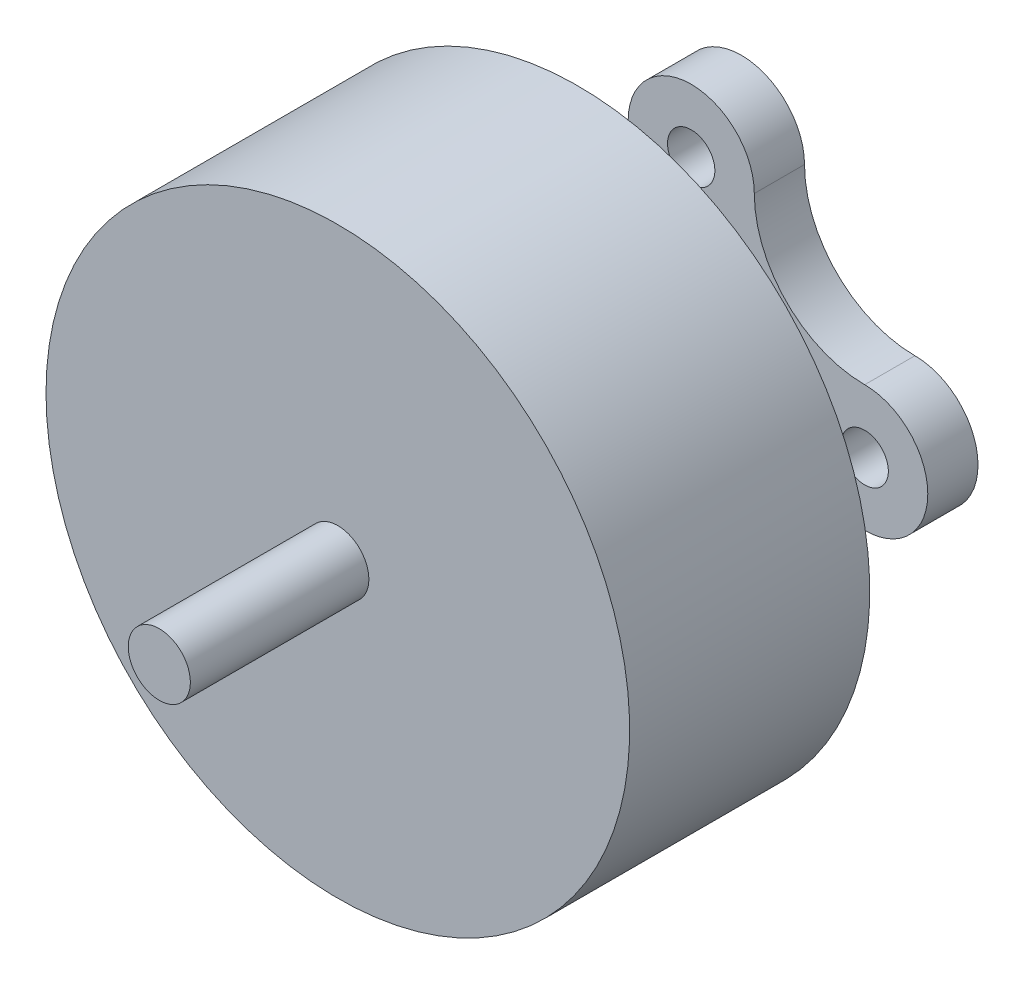
from build123d import *

# Parameters (mm, degrees)
SKETCH1_R           = 9.4
BOSS_EXTRUDE1_DEPTH = 13
SKETCH2_R           = 1
BOSS_EXTRUDE2_DEPTH = 5.75
SKETCH3_W           = 7.717079408
SKETCH3_H           = 3.649036098
SKETCH4_R           = 9.4
SKETCH4_R_2         = 0.762
CUT_EXTRUDE1_DEPTH  = 1.617316387


with BuildPart() as part:
    # Sketch1 → Boss-Extrude1 (new body)
    with BuildSketch(Plane.XY):
        with Locations(Location((0, 0, 0), (0, 0, 180))):
            Circle(SKETCH1_R)
    extrude(amount=BOSS_EXTRUDE1_DEPTH)

    # Sketch2 → Boss-Extrude2 (add)
    with BuildSketch(Plane.XY.offset(13)):
        Circle(SKETCH2_R)
    extrude(amount=BOSS_EXTRUDE2_DEPTH)

    # Sketch3 → Cut-Revolve1 (revolve, cut)
    with BuildSketch(Plane(origin=(0, 0, 0), x_dir=(1, 0, 0), z_dir=(0, 1, 0)), mode=Mode.PRIVATE) as cut_revolve1_sk:
        with Locations((5.541460296, -3.441834436)):
            Rectangle(SKETCH3_W, SKETCH3_H)
    revolve(cut_revolve1_sk.sketch.rotate(Axis((0, 0, 0), (0, 0, 1)), 180), axis=Axis((0, 0, 0), (0, 0, 1)), mode=Mode.SUBTRACT)

    # Sketch4 → Cut-Extrude1 (cut)
    with BuildSketch(Plane(origin=(0, 0, 0), x_dir=(-1, 0, 0), z_dir=(0, 0, -1))):
        Circle(SKETCH4_R)
        with BuildLine():
            ThreePointArc((-2.032, 5.588), (0, 7.62), (2.032, 5.588))
            ThreePointArc((2.032, 5.588), (3.073528286, 3.073528286), (5.588, 2.032))
            ThreePointArc((5.588, 2.032), (7.62, 0), (5.588, -2.032))
            ThreePointArc((5.588, -2.032), (3.073528286, -3.073528286), (2.032, -5.588))
            ThreePointArc((2.032, -5.588), (0, -7.62), (-2.032, -5.588))
            ThreePointArc((-2.032, -5.588), (-3.073528286, -3.073528286), (-5.588, -2.032))
            ThreePointArc((-5.588, -2.032), (-7.62, 0), (-5.588, 2.032))
            ThreePointArc((-5.588, 2.032), (-3.073528286, 3.073528286), (-2.032, 5.588))
        make_face(mode=Mode.SUBTRACT)
        with Locations((0, 5.588)):
            Circle(SKETCH4_R_2)
        with Locations((5.588, 0)):
            Circle(SKETCH4_R_2)
        with Locations((0, -5.588)):
            Circle(SKETCH4_R_2)
        with Locations((-5.588, 0)):
            Circle(SKETCH4_R_2)
    extrude(amount=-CUT_EXTRUDE1_DEPTH, mode=Mode.SUBTRACT)


solid = part.part
